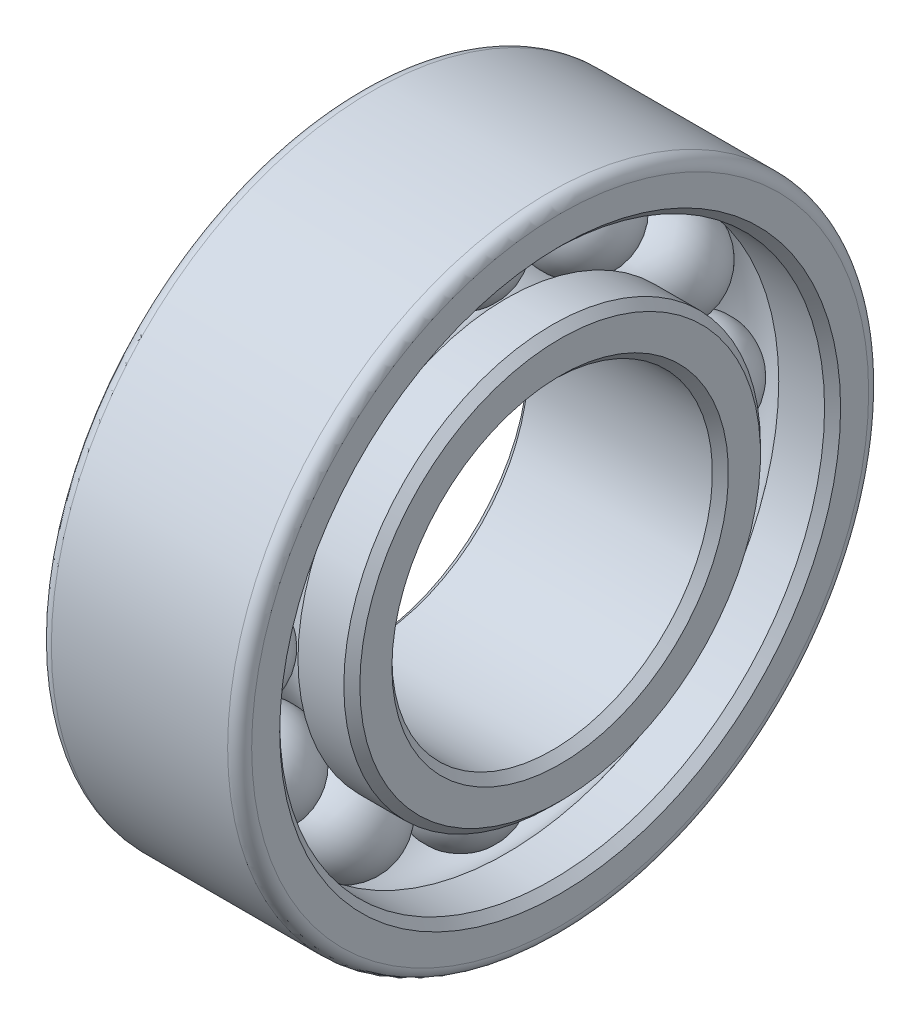
from build123d import *

# Parameters (mm, degrees)
PATTERN_CIRCULAR_5_COUNT = 12
FILLET_1_R               = 0.3
CHAMFER_1_SIZE           = 0.2
CHAMFER_2_SIZE           = 0.2


with BuildPart() as part:
    # Эскиз1 → Повернуть1 (revolve)
    with BuildSketch(Plane.XY):
        with BuildLine():
            Line((0, 0), (5, 0))
            Line((5, 0), (5, 1.2))
            Line((5, 1.2), (3.656369585, 1.2))
            ThreePointArc((3.656369585, 1.2), (2.510622896, 0.602596882), (1.364876207, 1.2))
            Line((1.364876207, 1.2), (0, 1.2))
            Line((0, 1.2), (0, 0))
        make_face()
        with BuildLine():
            Line((0, 2.8), (1.364876207, 2.8))
            ThreePointArc((1.364876207, 2.8), (2.510622896, 3.397403118), (3.656369585, 2.8))
            Line((3.656369585, 2.8), (5, 2.8))
            Line((5, 2.8), (5, 4))
            Line((5, 4), (0, 4))
            Line((0, 4), (0, 2.8))
        make_face()
    revolve(axis=Axis((-1.066901408, -4, 0), (1, 0, 0)))

    # Скругление1
    fillet_1_edges = [part.edges().sort_by_distance(p)[0] for p in [
        (0, -12, 0),
        (5, -12, 0),
    ]]
    fillet(fillet_1_edges, radius=FILLET_1_R)

    # Фаска1
    chamfer_1_edges = [part.edges().sort_by_distance(p)[0] for p in [
        (0, -9.2, 0),
        (5, -9.2, 0),
        (5, -8, 0),
        (0, -8, 0),
    ]]
    chamfer(chamfer_1_edges, length=CHAMFER_1_SIZE)

    # Фаска2
    chamfer_2_edges = [part.edges().sort_by_distance(p)[0] for p in [
        (5, -10.8, 0),
        (0, -10.8, 0),
    ]]
    chamfer(chamfer_2_edges, length=CHAMFER_2_SIZE)


with BuildPart() as body_2:
    # Эскиз2 → Повернуть2 (revolve)
    with BuildSketch(Plane.XY):
        with BuildLine():
            Line((2.510622896, 3.102596882), (2.510622896, 0.602596882))
            ThreePointArc((2.510622896, 0.602596882), (1.260622896, 1.852596882), (2.510622896, 3.102596882))
        make_face()
    revolve(axis=Axis((2.510622896, 3.102596882, 0), (0, -1, 0)))


with BuildPart() as pattern_circular_5_1:
    # Круговой массив5: pattern copy
    add(body_2.part.rotate(Axis((0, -4, 0), (1, 0, 0)), 1 * 360 / PATTERN_CIRCULAR_5_COUNT))


with BuildPart() as pattern_circular_5_2:
    # Круговой массив5: pattern copy
    add(body_2.part.rotate(Axis((0, -4, 0), (1, 0, 0)), 2 * 360 / PATTERN_CIRCULAR_5_COUNT))


with BuildPart() as pattern_circular_5_3:
    # Круговой массив5: pattern copy
    add(body_2.part.rotate(Axis((0, -4, 0), (1, 0, 0)), 3 * 360 / PATTERN_CIRCULAR_5_COUNT))


with BuildPart() as pattern_circular_5_4:
    # Круговой массив5: pattern copy
    add(body_2.part.rotate(Axis((0, -4, 0), (1, 0, 0)), 4 * 360 / PATTERN_CIRCULAR_5_COUNT))


with BuildPart() as pattern_circular_5_5:
    # Круговой массив5: pattern copy
    add(body_2.part.rotate(Axis((0, -4, 0), (1, 0, 0)), 5 * 360 / PATTERN_CIRCULAR_5_COUNT))


with BuildPart() as pattern_circular_5_6:
    # Круговой массив5: pattern copy
    add(body_2.part.rotate(Axis((0, -4, 0), (1, 0, 0)), 6 * 360 / PATTERN_CIRCULAR_5_COUNT))


with BuildPart() as pattern_circular_5_7:
    # Круговой массив5: pattern copy
    add(body_2.part.rotate(Axis((0, -4, 0), (1, 0, 0)), 7 * 360 / PATTERN_CIRCULAR_5_COUNT))


with BuildPart() as pattern_circular_5_8:
    # Круговой массив5: pattern copy
    add(body_2.part.rotate(Axis((0, -4, 0), (1, 0, 0)), 8 * 360 / PATTERN_CIRCULAR_5_COUNT))


with BuildPart() as pattern_circular_5_9:
    # Круговой массив5: pattern copy
    add(body_2.part.rotate(Axis((0, -4, 0), (1, 0, 0)), 9 * 360 / PATTERN_CIRCULAR_5_COUNT))


with BuildPart() as pattern_circular_5_10:
    # Круговой массив5: pattern copy
    add(body_2.part.rotate(Axis((0, -4, 0), (1, 0, 0)), 10 * 360 / PATTERN_CIRCULAR_5_COUNT))


with BuildPart() as pattern_circular_5_11:
    # Круговой массив5: pattern copy
    add(body_2.part.rotate(Axis((0, -4, 0), (1, 0, 0)), 11 * 360 / PATTERN_CIRCULAR_5_COUNT))


solid = Compound([part.part, body_2.part, pattern_circular_5_1.part, pattern_circular_5_2.part, pattern_circular_5_3.part, pattern_circular_5_4.part, pattern_circular_5_5.part, pattern_circular_5_6.part, pattern_circular_5_7.part, pattern_circular_5_8.part, pattern_circular_5_9.part, pattern_circular_5_10.part, pattern_circular_5_11.part])
